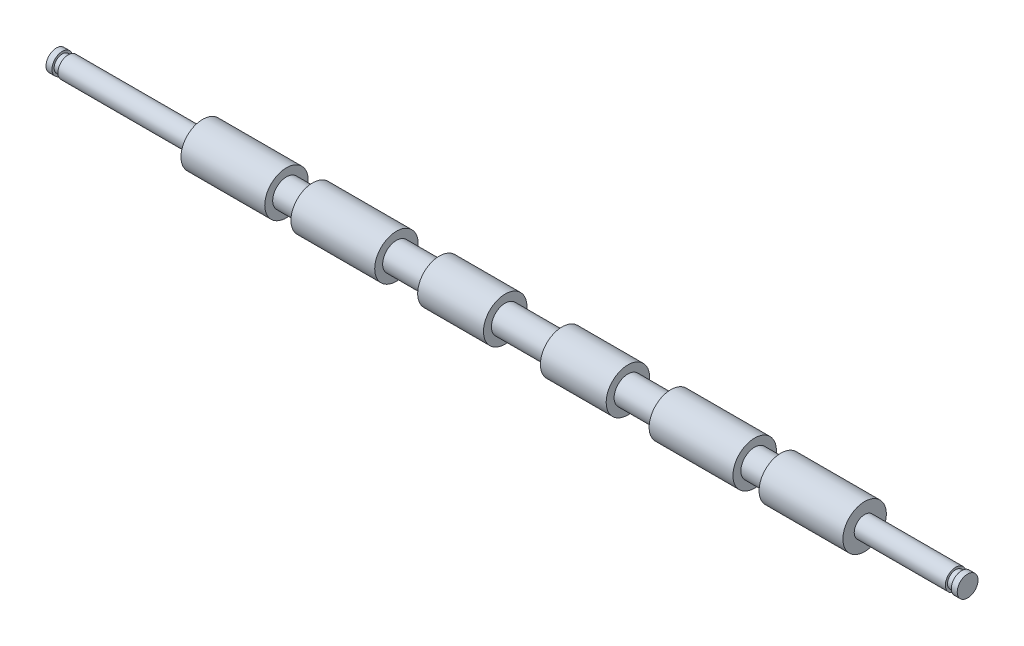
from build123d import *


with BuildPart() as part:
    # Esquisse1 → Révolution1 (revolve)
    with BuildSketch(Plane.XY):
        Polygon((0, 0), (0, 2.98), (1.7, 2.98), (1.7, 2.35), (3.4, 2.35), (3.4, 2.98), (41.9, 2.98), (41.9, 6.225), (65.9, 6.225), (65.9, 3.95), (73.4, 3.95), (73.4, 6.225), (97.4, 6.225), (97.4, 3.95), (109.7, 3.95), (109.7, 6.225), (128.55, 6.225), (128.55, 3.95), (144.85, 3.95), (144.85, 6.225), (163.7, 6.225), (163.7, 3.95), (176, 3.95), (176, 6.225), (200, 6.225), (200, 3.95), (207.5, 3.95), (207.5, 6.225), (231.5, 6.225), (231.5, 2.98), (257.6, 2.98), (257.6, 2.35), (259.3, 2.35), (259.3, 2.98), (261, 2.98), (261, 0), align=None)
    revolve(axis=Axis((0, 0, 0), (1, 0, 0)))


solid = part.part
